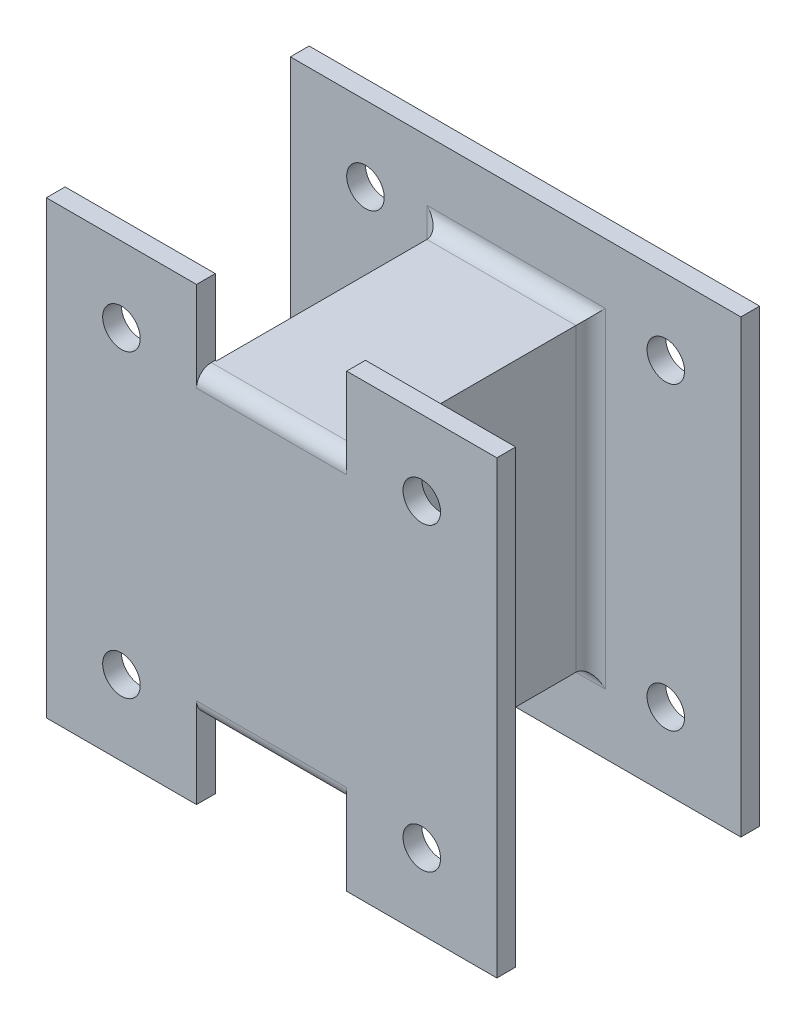
from build123d import *

# Parameters (mm, degrees)
SKETCH1_W           = 152.4
SKETCH1_H           = 152.4
SKETCH1_R           = 6.35
BOSS_EXTRUDE1_DEPTH = 6.35
SKETCH2_W           = 50.4
SKETCH2_H           = 101.6
BOSS_EXTRUDE2_DEPTH = 76.2
SKETCH3_R           = 6.35
BOSS_EXTRUDE3_DEPTH = 6.35
FILLET2_R           = 5
FILLET6_R           = 5


with BuildPart() as part:
    # Sketch1 → Boss-Extrude1 (new body)
    with BuildSketch(Plane.XY):
        with Locations((76.2, 76.2)):
            Rectangle(SKETCH1_W, SKETCH1_H)
        with Locations((25.4, 127)):
            Circle(SKETCH1_R, mode=Mode.SUBTRACT)
        with Locations((127, 127)):
            Circle(SKETCH1_R, mode=Mode.SUBTRACT)
        with Locations((127, 25.4)):
            Circle(SKETCH1_R, mode=Mode.SUBTRACT)
        with Locations((25.4, 25.4)):
            Circle(SKETCH1_R, mode=Mode.SUBTRACT)
    extrude(amount=BOSS_EXTRUDE1_DEPTH)

    # Sketch2 → Boss-Extrude2 (add)
    with BuildSketch(Plane.XY.offset(6.35)):
        with Locations((76.4, 76.2)):
            Rectangle(SKETCH2_W, SKETCH2_H)
    extrude(amount=BOSS_EXTRUDE2_DEPTH)

    # Sketch3 → Boss-Extrude3 (add)
    with BuildSketch(Plane.XY.offset(82.55)):
        Polygon((101.6, 152.4), (152.4, 152.4), (152.4, 0), (101.6, 0), (101.6, 25.4), (50.8, 25.4), (50.8, 0), (0, 0), (0, 152.4), (50.8, 152.4), (50.8, 127), (101.6, 127), align=None)
        with Locations((25.4, 127)):
            Circle(SKETCH3_R, mode=Mode.SUBTRACT)
        with Locations((127, 127)):
            Circle(SKETCH3_R, mode=Mode.SUBTRACT)
        with Locations((127, 25.4)):
            Circle(SKETCH3_R, mode=Mode.SUBTRACT)
        with Locations((25.4, 25.4)):
            Circle(SKETCH3_R, mode=Mode.SUBTRACT)
    extrude(amount=BOSS_EXTRUDE3_DEPTH)

    # Fillet2
    fillet2_edges = [part.edges().sort_by_distance(p)[0] for p in [
        (76.4, 25.4, 6.35),
        (51.2, 76.2, 6.35),
        (76.4, 127, 6.35),
        (101.6, 76.2, 6.35),
    ]]
    fillet(fillet2_edges, radius=FILLET2_R)

    # Fillet6
    fillet6_edges = [part.edges().sort_by_distance(p)[0] for p in [
        (76.2, 25.4, 88.9),
        (76.2, 127, 88.9),
    ]]
    fillet(fillet6_edges, radius=FILLET6_R)


solid = part.part
